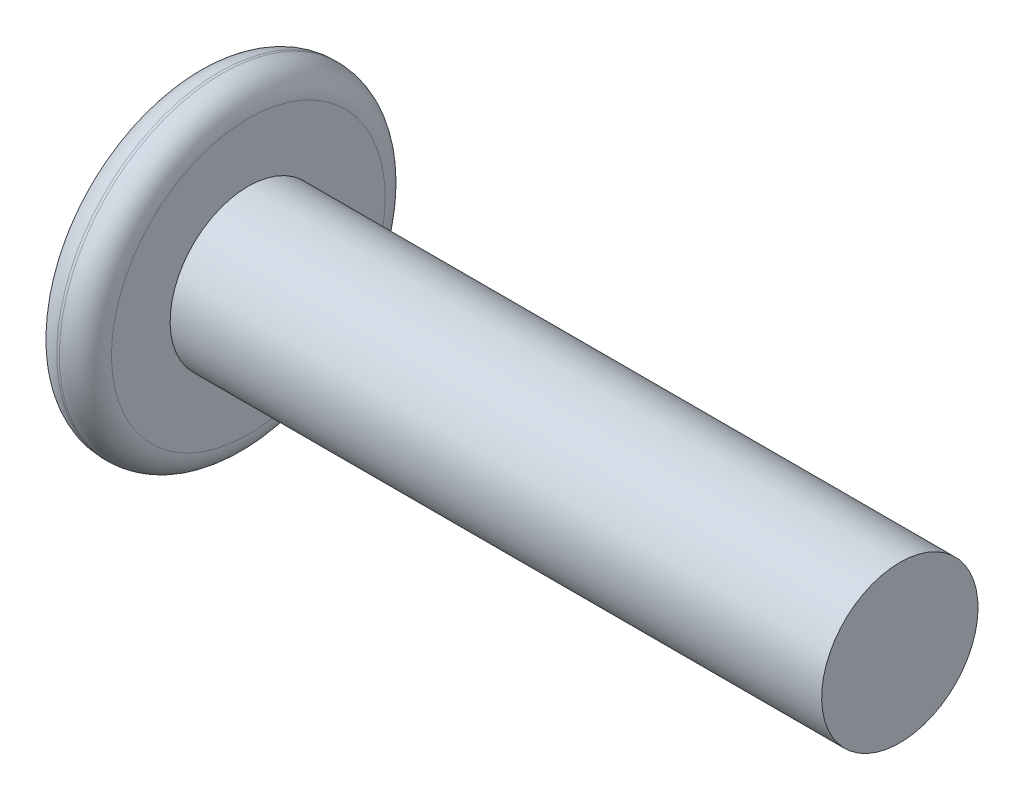
from build123d import *

# Parameters (mm, degrees)
FILLET_1_R          = 1
CUT_EXTRUDE_1_DEPTH = 1


with BuildPart() as part:
    # 草图1 → 旋转1 (revolve)
    with BuildSketch(Plane.XY):
        Polygon((0, 0), (0, 6.25), (2.1, 6.25), (2.1, 3), (27.1, 3), (27.1, 0), align=None)
    revolve(axis=Axis((27.1, 0, 0), (-1, 0, 0)))

    # 圆角1
    fillet_1_edges = [part.edges().sort_by_distance(p)[0] for p in [
        (2.1, -6.25, 0),
        (0, -6.25, 0),
    ]]
    fillet(fillet_1_edges, radius=FILLET_1_R)

    # 草图2 → 切除-拉伸1 (cut)
    with BuildSketch(Plane.ZY):
        Polygon((1.154700538, 2), (-1.154700538, 2), (-2.309401077, 0), (-1.154700538, -2), (1.154700538, -2), (2.309401077, 0), align=None)
    extrude(amount=-CUT_EXTRUDE_1_DEPTH, mode=Mode.SUBTRACT)


solid = part.part
